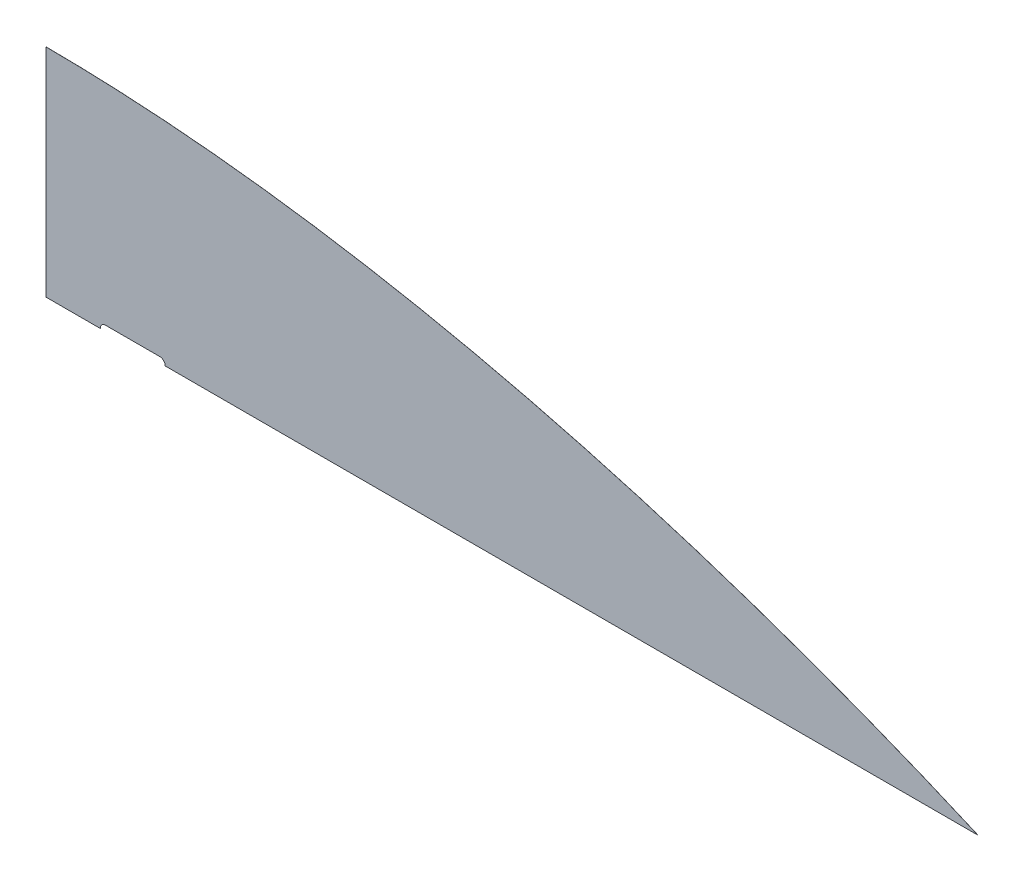
from build123d import *

# Parameters (mm, degrees)
BOSS_EXTRUDE1_DEPTH = 0.127
CUT_EXTRUDE2_DEPTH  = 1.1270001


with BuildPart() as part:
    # Sketch1 → Boss-Extrude1 (new body)
    with BuildSketch(Plane.XY):
        with BuildLine():
            Line((0, 254), (0, 0))
            Line((0, 0), (1092.2, 0))
            add(Edge.make_bspline(
                [(0, 254), (376.513153864, 252.276375478), (770.285770075, 140.499670678), (1092.2, 0)],
                knots=[0, 0, 0, 0, 1, 1, 1, 1], degree=3))
        make_face()
    extrude(amount=BOSS_EXTRUDE1_DEPTH)

    # Sketch7 → Cut-Extrude2 (cut, through all)
    with BuildSketch(Plane(origin=(0, 0, 0), x_dir=(-1, 0, 0), z_dir=(0, 0, -1))):
        with BuildLine():
            Line((-133.35, 0), (-63.5, 0))
            ThreePointArc((-63.5, 0), (-65.359871939, 4.490128061), (-69.85, 6.35))
            Line((-69.85, 6.35), (-133.35, 6.35))
            ThreePointArc((-133.35, 6.35), (-137.840128061, 4.490128061), (-139.7, 0))
            Line((-139.7, 0), (-133.35, 0))
        make_face()
    extrude(amount=-CUT_EXTRUDE2_DEPTH, mode=Mode.SUBTRACT)


solid = part.part
